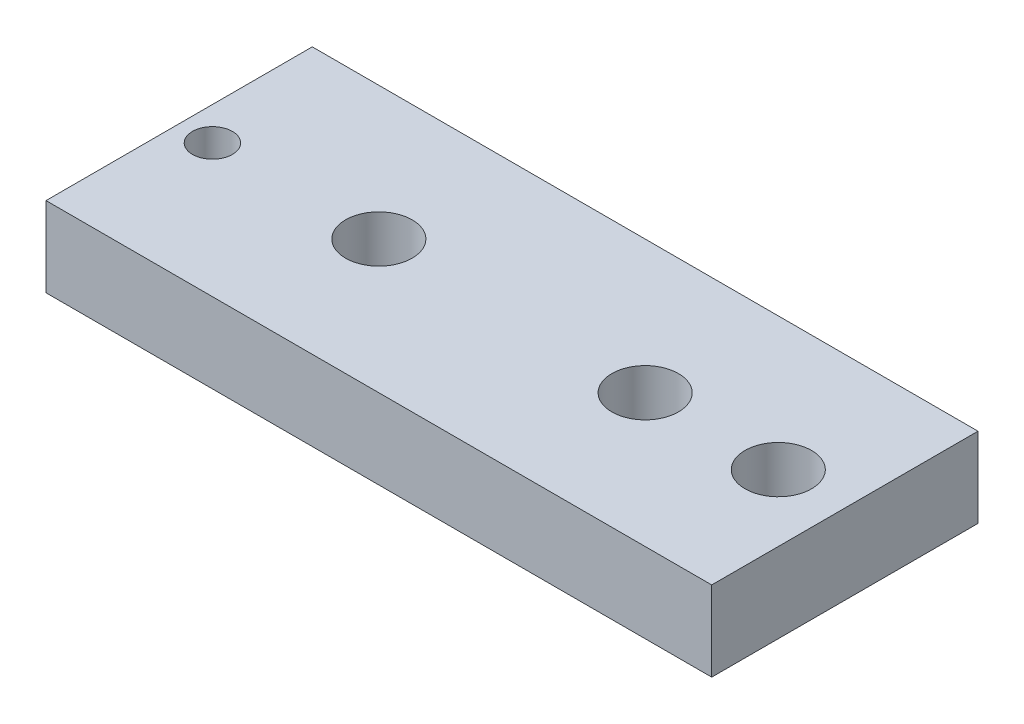
from build123d import *

# Parameters (mm, degrees)
SKETCH1_W           = 50
SKETCH1_H           = 20
BOSS_EXTRUDE1_DEPTH = 6
SKETCH1_3_R         = 2.5
SKETCH1_3_R_2       = 1.5
CUT_EXTRUDE1_DEPTH  = 6


with BuildPart() as part:
    # Sketch1 → Boss-Extrude1 (new body)
    with BuildSketch(Plane(origin=(0, 0, 0), x_dir=(1, 0, 0), z_dir=(0, 1, 0))):
        Rectangle(SKETCH1_W, SKETCH1_H)
    extrude(amount=BOSS_EXTRUDE1_DEPTH)

    # Sketch1_3 → Cut-Extrude1 (cut)
    with BuildSketch(Plane(origin=(0, 0, 0), x_dir=(1, 0, 0), z_dir=(0, 1, 0))):
        with Locations((20, 0)):
            Circle(SKETCH1_3_R)
        with Locations((-10, 0)):
            Circle(SKETCH1_3_R)
        with Locations((10, 0)):
            Circle(SKETCH1_3_R)
        with Locations((-22.5, 0)):
            Circle(SKETCH1_3_R_2)
    extrude(amount=CUT_EXTRUDE1_DEPTH, mode=Mode.SUBTRACT)


solid = part.part
